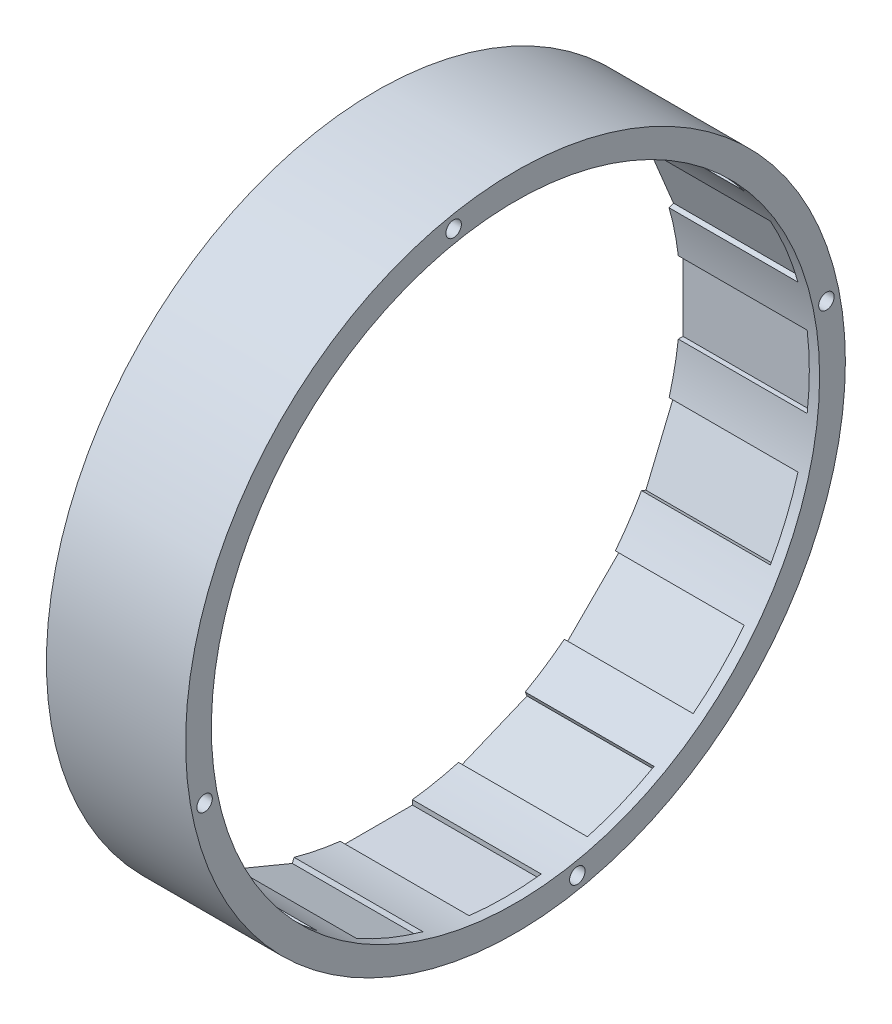
from build123d import *

# Parameters (mm, degrees)
SKETCH1_R           = 64
SKETCH1_R_2         = 59
BOSS_EXTRUDE1_DEPTH = 27
SKETCH2_W           = 14
SKETCH2_H           = 59.5
CUT_EXTRUDE1_DEPTH  = 25
CIRPATTERN1_COUNT   = 16
SKETCH3_R           = 1.5
CUT_EXTRUDE2_DEPTH  = 28
CIRPATTERN2_COUNT   = 4


with BuildPart() as part:
    # Sketch1 → Boss-Extrude1 (new body)
    with BuildSketch(Plane(origin=(0, 0, 0), x_dir=(0, 0, -1), z_dir=(1, 0, 0))):
        Circle(SKETCH1_R)
        Circle(SKETCH1_R_2, mode=Mode.SUBTRACT)
    extrude(amount=BOSS_EXTRUDE1_DEPTH)

    # Sketch2 → Cut-Extrude1 (cut)
    with BuildSketch(Plane.ZY):
        with Locations((0, 29.75)):
            Rectangle(SKETCH2_W, SKETCH2_H)
    cut_extrude1 = extrude(amount=-CUT_EXTRUDE1_DEPTH, mode=Mode.SUBTRACT)

    # CirPattern1: Cut-Extrude1 ×16 about axis
    cirpattern1_axis = Axis((0, 0, 0), (1, 0, 0))
    for i in range(1, CIRPATTERN1_COUNT):
        add(cut_extrude1.rotate(cirpattern1_axis, i * 360 / CIRPATTERN1_COUNT), mode=Mode.SUBTRACT)

    # Sketch3 → Cut-Extrude2 (cut, through all)
    with BuildSketch(Plane.ZY):
        with Locations((11.998054804, 60.318294745)):
            Circle(SKETCH3_R)
    cut_extrude2 = extrude(amount=-CUT_EXTRUDE2_DEPTH, mode=Mode.SUBTRACT)

    # CirPattern2: Cut-Extrude2 ×4 about axis
    cirpattern2_axis = Axis((0, 0, 0), (1, 0, 0))
    for i in range(1, CIRPATTERN2_COUNT):
        add(cut_extrude2.rotate(cirpattern2_axis, i * 360 / CIRPATTERN2_COUNT), mode=Mode.SUBTRACT)


solid = part.part
